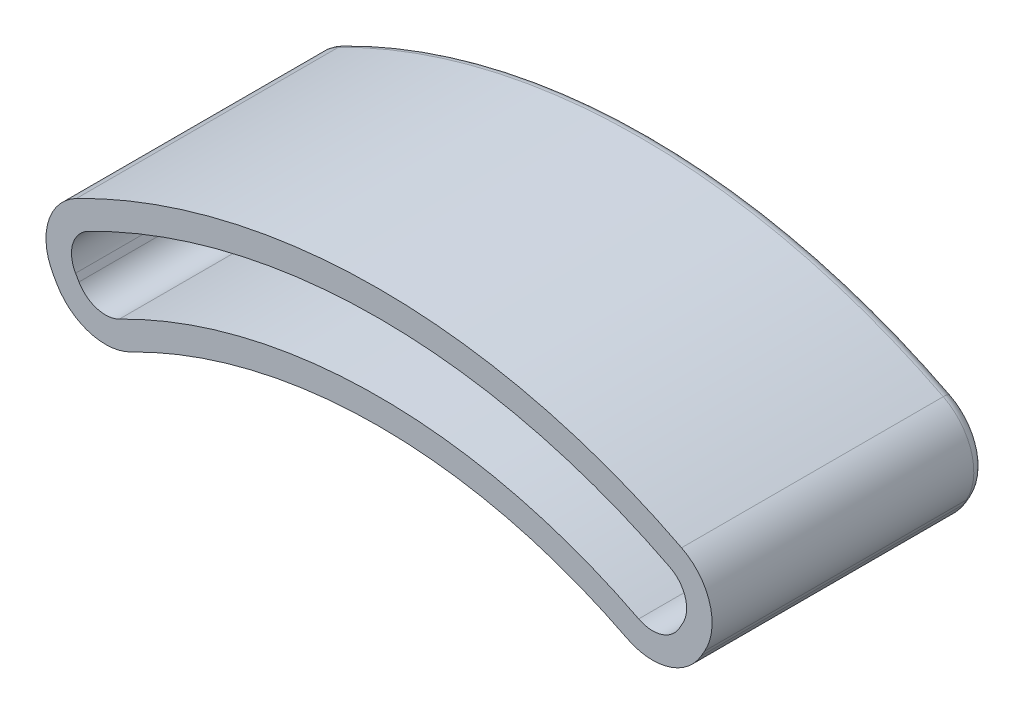
from build123d import *

# Parameters (mm, degrees)
EXTRUDE_THIN2_DEPTH = 20.32
FILLET2_R           = 0.762


with BuildPart() as part:
    # Sketch1 → Extrude-Thin2 (new body)
    with BuildSketch(Plane.XY):
        with BuildLine():
            Line((24.32799261, 38.327319246), (24.073666549, 37.886813588))
            ThreePointArc((24.073666549, 37.886813588), (21.631585853, 35.963049129), (18.536136228, 36.250832801))
            ThreePointArc((18.536136228, 36.250832801), (0, 40.715), (-18.536136228, 36.250832801))
            ThreePointArc((-18.536136228, 36.250832801), (-21.631585853, 35.963049129), (-24.073666549, 37.886813588))
            Line((-24.073666549, 37.886813588), (-24.32799261, 38.327319246))
            ThreePointArc((-24.32799261, 38.327319246), (-24.718082956, 41.60910514), (-22.608625258, 44.153211536))
            ThreePointArc((-22.608625258, 44.153211536), (0, 49.605), (22.608625258, 44.153211536))
            ThreePointArc((22.608625258, 44.153211536), (24.718082956, 41.60910514), (24.32799261, 38.327319246))
        make_face()
        with BuildLine():
            Line((22.678214215, 39.279819246), (22.423888155, 38.839313588))
            ThreePointArc((22.423888155, 38.839313588), (21.091844139, 37.78998752), (19.403417071, 37.946960431))
            ThreePointArc((19.403417071, 37.946960431), (0, 42.62), (-19.403417071, 37.946960431))
            ThreePointArc((-19.403417071, 37.946960431), (-21.091844139, 37.78998752), (-22.423888155, 38.839313588))
            Line((-22.423888155, 38.839313588), (-22.678214215, 39.279819246))
            ThreePointArc((-22.678214215, 39.279819246), (-22.890990768, 41.069884279), (-21.740377478, 42.457578677))
            ThreePointArc((-21.740377478, 42.457578677), (0, 47.7), (21.740377478, 42.457578677))
            ThreePointArc((21.740377478, 42.457578677), (22.890990768, 41.069884279), (22.678214215, 39.279819246))
        make_face(mode=Mode.SUBTRACT)
    extrude(amount=EXTRUDE_THIN2_DEPTH)

    # Fillet2
    fillet2_edges = [part.edges().sort_by_distance(p)[0] for p in [
        (-21.091844139, 37.78998752, 0),
        (0, 42.62, 0),
        (21.091844139, 37.78998752, 0),
        (22.551051185, 39.059566417, 0),
        (22.890990768, 41.069884279, 0),
        (0, 47.7, 0),
        (-22.890990768, 41.069884279, 0),
        (-22.551051185, 39.059566417, 0),
        (-24.20082958, 38.107066417, 0),
        (-24.718082956, 41.60910514, 0),
        (0, 49.605, 0),
        (24.718082956, 41.60910514, 0),
        (24.20082958, 38.107066417, 0),
        (21.631585853, 35.963049129, 0),
        (0, 40.715, 0),
        (-21.631585853, 35.963049129, 0),
    ]]
    fillet(fillet2_edges, radius=FILLET2_R)


solid = part.part
